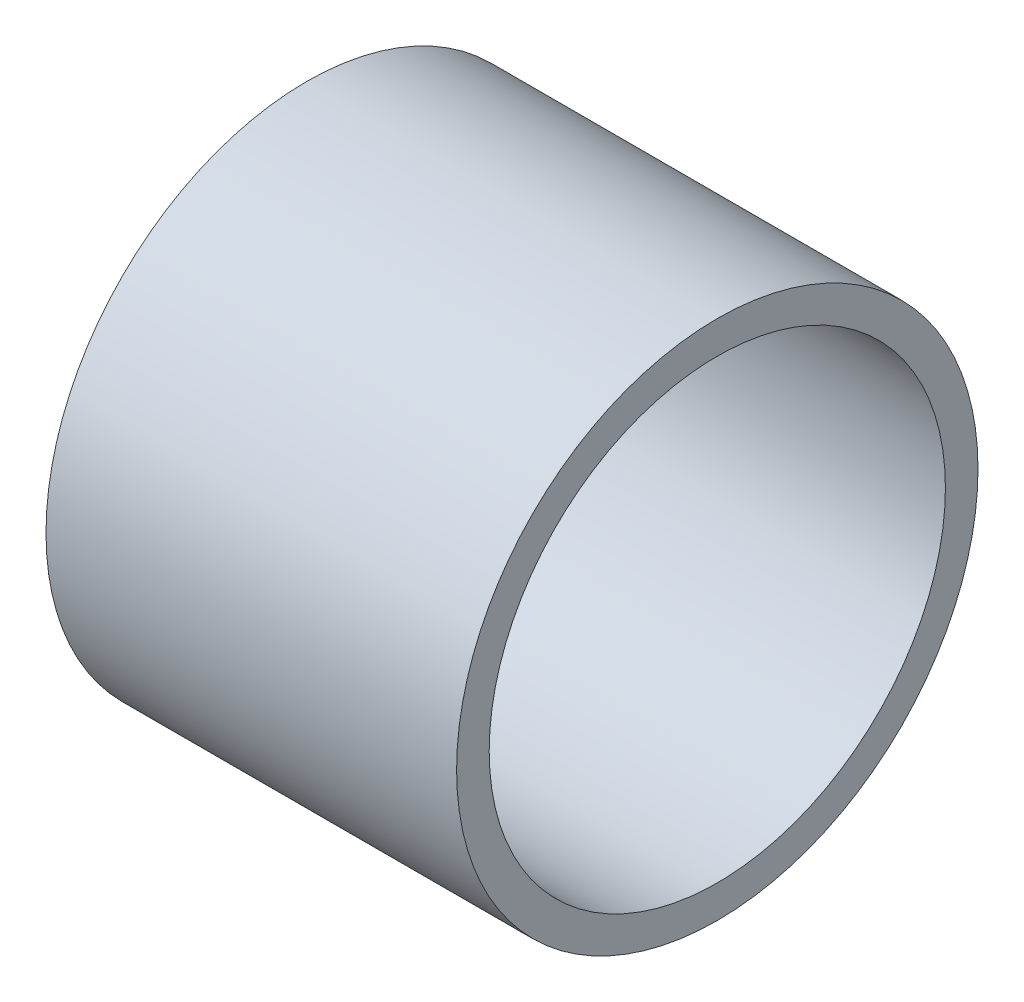
from build123d import *

# Parameters (mm, degrees)
BOSS_EXTRUDE1_DEPTH      = 6.3
BOSS_EXTRUDE1_DEPTH_BACK = 6.3
SKETCH1_R                = 8
SKETCH1_R_2              = 7


with BuildPart() as part:
    # Sketch1 → Boss-Extrude1 (new, two sides: drawn at the far end of the back side and taken through both)
    with BuildSketch(Plane(origin=(0, 0, 0), x_dir=(0, 0, -1), z_dir=(1, 0, 0)).offset(-BOSS_EXTRUDE1_DEPTH_BACK)):
        Circle(SKETCH1_R)
        Circle(SKETCH1_R_2, mode=Mode.SUBTRACT)
    extrude(amount=BOSS_EXTRUDE1_DEPTH + BOSS_EXTRUDE1_DEPTH_BACK)


solid = part.part
